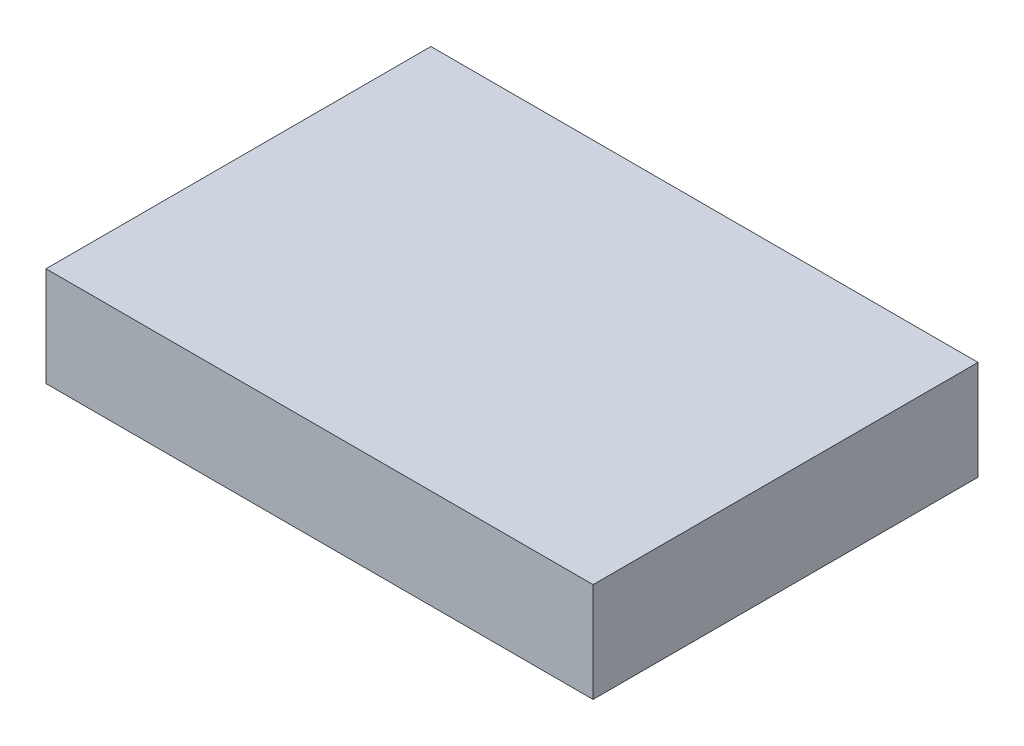
from build123d import *

# Parameters (mm, degrees)
SKETCH1_W           = 25.3
SKETCH1_H           = 17.8
BOSS_EXTRUDE1_DEPTH = 2.3


with BuildPart() as part:
    # Sketch1 → Boss-Extrude1 (new body, symmetric)
    with BuildSketch(Plane(origin=(0, 0, 0), x_dir=(1, 0, 0), z_dir=(0, 1, 0))):
        Rectangle(SKETCH1_W, SKETCH1_H)
    extrude(amount=BOSS_EXTRUDE1_DEPTH, both=True)


solid = part.part
